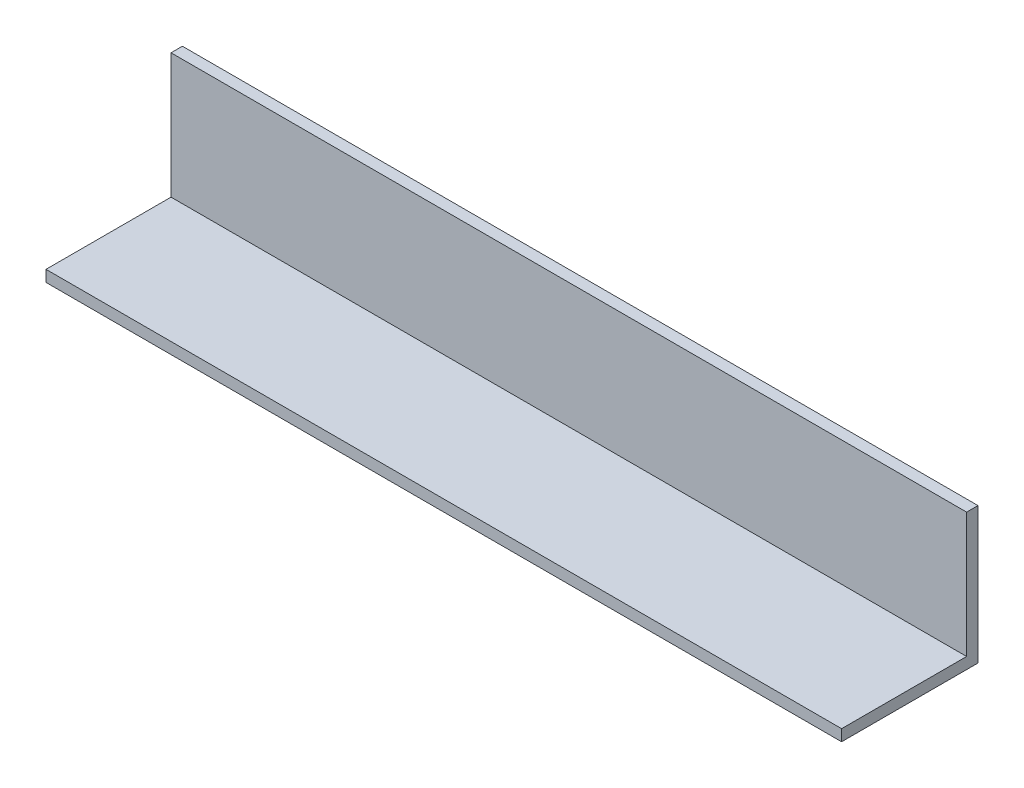
from build123d import *

# Parameters (mm, degrees)
SKETCH1_W           = 222.25
SKETCH1_H           = 38.1
BOSS_EXTRUDE1_DEPTH = 38.1
SKETCH2_W           = 222.25
SKETCH2_H           = 34.925
CUT_EXTRUDE1_DEPTH  = 34.925


with BuildPart() as part:
    # Sketch1 → Boss-Extrude1 (new body)
    with BuildSketch(Plane.XY):
        with Locations((74.312162162, 3.595472973)):
            Rectangle(SKETCH1_W, SKETCH1_H)
    extrude(amount=BOSS_EXTRUDE1_DEPTH)

    # Sketch2 → Cut-Extrude1 (cut)
    with BuildSketch(Plane.XY.offset(38.1)):
        with Locations((74.312162162, 5.182972973)):
            Rectangle(SKETCH2_W, SKETCH2_H)
    extrude(amount=-CUT_EXTRUDE1_DEPTH, mode=Mode.SUBTRACT)


solid = part.part
